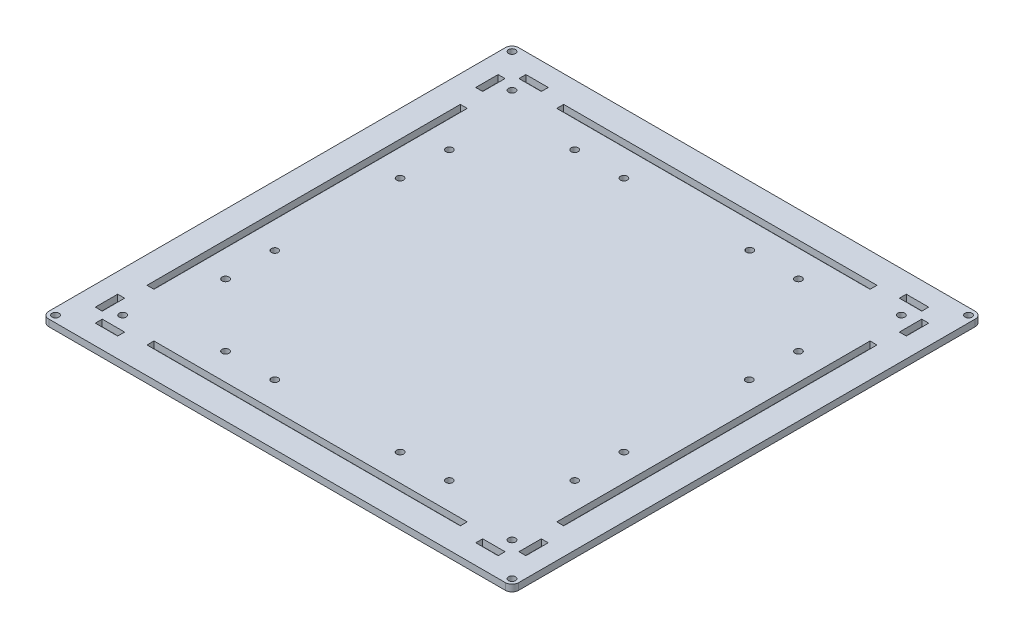
from build123d import *

# Parameters (mm, degrees)
SKETCH_3_R      = 1.55
SKETCH_3_W      = 10
SKETCH_3_H      = 3.1
SKETCH_3_W_2    = 3.1
SKETCH_3_H_2    = 10
SKETCH_3_W_3    = 140
SKETCH_3_H_3    = 140
EXTRUDE_1_DEPTH = 3


with BuildPart() as part:
    # 草图3 → 凸台-拉伸1 (new body)
    with BuildSketch(Plane(origin=(0, 0, 0), x_dir=(1, 0, 0), z_dir=(0, 1, 0))):
        with BuildLine():
            ThreePointArc((0, 3), (0.878679656, 0.878679656), (3, 0))
            Line((3, 0), (207, 0))
            ThreePointArc((207, 0), (209.121320344, 0.878679656), (210, 3))
            Line((210, 3), (210, 207))
            ThreePointArc((210, 207), (209.121320344, 209.121320344), (207, 210))
            Line((207, 210), (3, 210))
            ThreePointArc((3, 210), (0.878679656, 209.121320344), (0, 207))
            Line((0, 207), (0, 3))
        make_face()
        with Locations((3, 3)):
            Circle(SKETCH_3_R, mode=Mode.SUBTRACT)
        with Locations((20, 10.35)):
            Rectangle(SKETCH_3_W, SKETCH_3_H, mode=Mode.SUBTRACT)
        with Locations((10.35, 20)):
            Rectangle(SKETCH_3_W_2, SKETCH_3_H_2, mode=Mode.SUBTRACT)
        with Locations((190, 10.35)):
            Rectangle(SKETCH_3_W, SKETCH_3_H, mode=Mode.SUBTRACT)
        with Locations((207, 3)):
            Circle(SKETCH_3_R, mode=Mode.SUBTRACT)
        with Locations((199.65, 20)):
            Rectangle(SKETCH_3_W_2, SKETCH_3_H_2, mode=Mode.SUBTRACT)
        with Locations((105, 196.55)):
            Rectangle(SKETCH_3_W_3, SKETCH_3_H, mode=Mode.SUBTRACT)
        Polygon((11.9, 175), (15, 175), (15, 87), (15, 35), (11.9, 35), align=None, mode=Mode.SUBTRACT)
        with Locations((105, 13.45)):
            Rectangle(SKETCH_3_W_3, SKETCH_3_H, mode=Mode.SUBTRACT)
        with Locations((196.55, 105)):
            Rectangle(SKETCH_3_W_2, SKETCH_3_H_3, mode=Mode.SUBTRACT)
        with Locations((10.35, 190)):
            Rectangle(SKETCH_3_W_2, SKETCH_3_H_2, mode=Mode.SUBTRACT)
        with Locations((3, 207)):
            Circle(SKETCH_3_R, mode=Mode.SUBTRACT)
        with Locations((20, 199.65)):
            Rectangle(SKETCH_3_W, SKETCH_3_H, mode=Mode.SUBTRACT)
        with Locations((199.65, 190)):
            Rectangle(SKETCH_3_W_2, SKETCH_3_H_2, mode=Mode.SUBTRACT)
        with Locations((190, 199.65)):
            Rectangle(SKETCH_3_W, SKETCH_3_H, mode=Mode.SUBTRACT)
        with Locations((207, 207)):
            Circle(SKETCH_3_R, mode=Mode.SUBTRACT)
        with BuildLine():
            ThreePointArc((133, 184.80254627), (134.55, 183.25254627), (133, 181.70254627))
            ThreePointArc((133, 181.70254627), (131.45, 183.25254627), (133, 184.80254627))
        make_face(mode=Mode.SUBTRACT)
        with Locations((155, 183)):
            Circle(SKETCH_3_R, mode=Mode.SUBTRACT)
        with Locations((192, 192)):
            Circle(SKETCH_3_R, mode=Mode.SUBTRACT)
        with Locations((18, 18)):
            Circle(SKETCH_3_R, mode=Mode.SUBTRACT)
        with Locations((55, 27)):
            Circle(SKETCH_3_R, mode=Mode.SUBTRACT)
        with Locations((77, 27)):
            Circle(SKETCH_3_R, mode=Mode.SUBTRACT)
        with Locations((27, 55)):
            Circle(SKETCH_3_R, mode=Mode.SUBTRACT)
        with Locations((27, 77)):
            Circle(SKETCH_3_R, mode=Mode.SUBTRACT)
        with Locations((133, 27)):
            Circle(SKETCH_3_R, mode=Mode.SUBTRACT)
        with Locations((155, 27)):
            Circle(SKETCH_3_R, mode=Mode.SUBTRACT)
        with Locations((192, 18)):
            Circle(SKETCH_3_R, mode=Mode.SUBTRACT)
        with Locations((183, 55)):
            Circle(SKETCH_3_R, mode=Mode.SUBTRACT)
        with Locations((183, 77)):
            Circle(SKETCH_3_R, mode=Mode.SUBTRACT)
        with Locations((27, 133)):
            Circle(SKETCH_3_R, mode=Mode.SUBTRACT)
        with Locations((27, 155)):
            Circle(SKETCH_3_R, mode=Mode.SUBTRACT)
        with Locations((18, 192)):
            Circle(SKETCH_3_R, mode=Mode.SUBTRACT)
        with Locations((55, 183)):
            Circle(SKETCH_3_R, mode=Mode.SUBTRACT)
        with Locations((77, 183)):
            Circle(SKETCH_3_R, mode=Mode.SUBTRACT)
        with Locations((183, 133)):
            Circle(SKETCH_3_R, mode=Mode.SUBTRACT)
        with Locations((183, 155)):
            Circle(SKETCH_3_R, mode=Mode.SUBTRACT)
    extrude(amount=EXTRUDE_1_DEPTH)


solid = part.part
